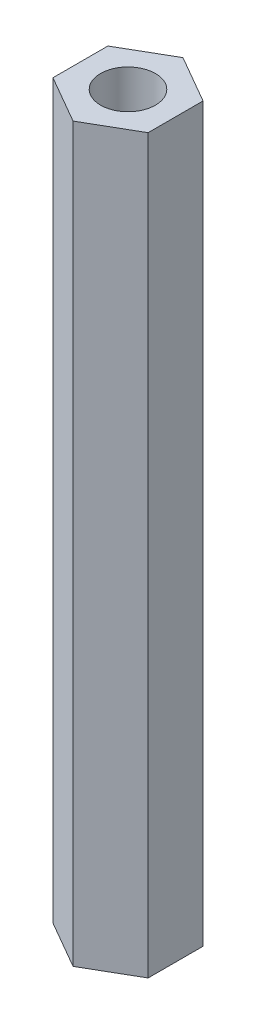
from build123d import *

# Parameters (mm, degrees)
SKETCH1_R           = 1.5
BOSS_EXTRUDE2_DEPTH = 40


with BuildPart() as part:
    # Sketch1 → Boss-Extrude2 (new body)
    with BuildSketch(Plane(origin=(0, 0, 0), x_dir=(1, 0, 0), z_dir=(0, 1, 0))):
        Polygon((0, 3.0022214), (-2.6, 1.5011107), (-2.6, -1.5011107), (0, -3.0022214), (2.6, -1.5011107), (2.6, 1.5011107), align=None)
        Circle(SKETCH1_R, mode=Mode.SUBTRACT)
    extrude(amount=BOSS_EXTRUDE2_DEPTH)


solid = part.part
